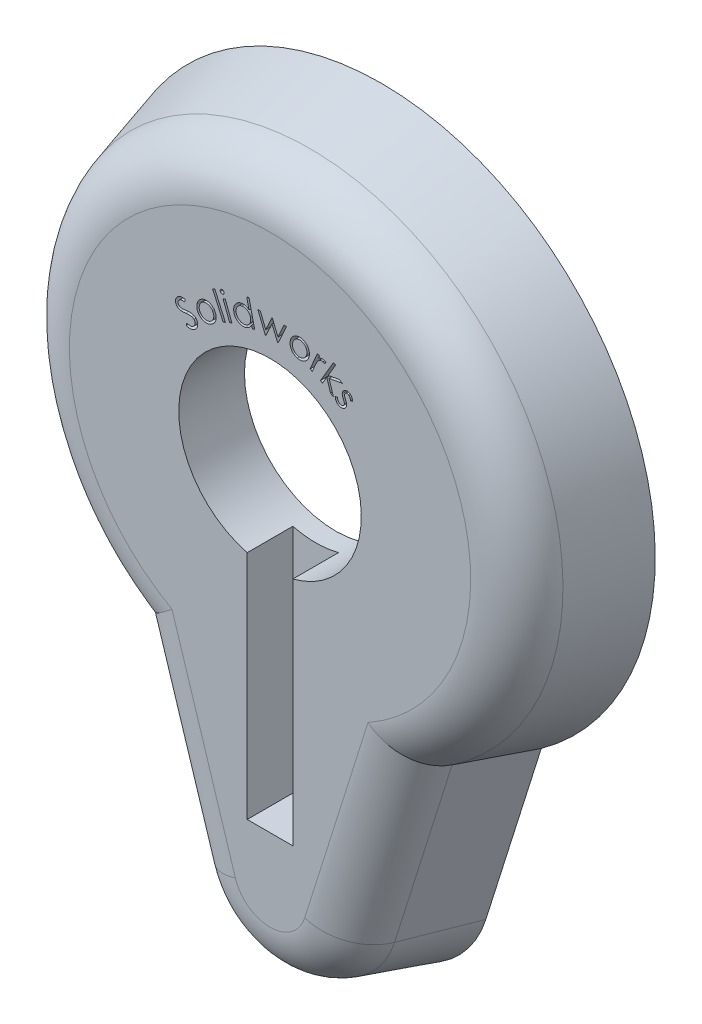
from build123d import *

# Parameters (mm, degrees)
BOSS_EXTRUDE1_DEPTH = 15.494
BOSS_EXTRUDE1_DRAFT = 16
FILLET2_R           = 7.62
CUT_EXTRUDE1_DEPTH  = 6.35
SKETCH3_R           = 12.7
CUT_EXTRUDE3_DEPTH  = 21.336
SKETCH5_W           = 6.35
SKETCH5_H           = 50.8
CUT_EXTRUDE11_DEPTH = 6.35
CUT_EXTRUDE12_DEPTH = 6.35


with BuildPart() as part:
    # Sketch1 → Boss-Extrude1 (with draft: the straight prism first)
    with BuildSketch(Plane.XY):
        with BuildLine():
            Line((-22.24375236, -18.70816137), (-14.534646329, -43.158321986))
            ThreePointArc((-14.534646329, -43.158321986), (0, -53.815565602), (14.534646329, -43.158321986))
            Line((14.534646329, -43.158321986), (22.24375236, -18.70816137))
            ThreePointArc((22.24375236, -18.70816137), (0, 50.324434398), (-22.24375236, -18.70816137))
        make_face()
    extrude(amount=BOSS_EXTRUDE1_DEPTH)
    # Boss-Extrude1: the draft: its side faces are tilted about the plane it starts from
    boss_extrude1_sides = [part.faces().sort_by_distance(p)[0] for p in [
        (0, 50.324434398, 7.747),
        (-18.389199344, -30.933241678, 7.747),
        (0, -53.815565602, 7.747),
        (18.389199344, -30.933241678, 7.747),
    ]]
    draft(boss_extrude1_sides, Plane.XY, BOSS_EXTRUDE1_DRAFT)

    # Fillet2
    fillet2_edges = [part.edges().sort_by_distance(p)[0] for p in [
        (-14.38177278, -28.868491464, 15.494),
        (14.38177278, -28.868491464, 15.494),
        (0, -49.372732595, 15.494),
        (0, 45.881601391, 15.494),
    ]]
    fillet(fillet2_edges, radius=FILLET2_R)

    # Sketch2 → Cut-Extrude1 (cut)
    with BuildSketch(Plane(origin=(0, 0, 0), x_dir=(-1, 0, 0), z_dir=(0, 0, -1))):
        with BuildLine():
            Line((-20.080125275, -17.123515598), (-12.112205275, -42.394529256))
            ThreePointArc((-12.112205275, -42.394529256), (0, -51.275565602), (12.112205275, -42.394529256))
            Line((12.112205275, -42.394529256), (20.080125275, -17.123515598))
            ThreePointArc((20.080125275, -17.123515598), (0, 47.784434398), (-20.080125275, -17.123515598))
        make_face()
    extrude(amount=-CUT_EXTRUDE1_DEPTH, mode=Mode.SUBTRACT)

    # Sketch3 → Cut-Extrude3 (cut)
    with BuildSketch(Plane.XY.offset(15.494)):
        with Locations((0, 12.224434398)):
            Circle(SKETCH3_R)
    extrude(amount=-CUT_EXTRUDE3_DEPTH, mode=Mode.SUBTRACT)

    # Sketch5 → Cut-Extrude11 (cut)
    with BuildSketch(Plane.XY.offset(15.494)):
        with Locations((0, -6.825565602)):
            Rectangle(SKETCH5_W, SKETCH5_H)
    extrude(amount=-CUT_EXTRUDE11_DEPTH, mode=Mode.SUBTRACT)

    # Sketch7 → Cut-Extrude12 (cut)
    with BuildSketch(Plane.XY.offset(15.494)):
        with BuildLine():
            Line((-11.659564973, 23.051406122), (-11.565614653, 23.383737852))
            add(Edge.make_bspline(
                [(-11.565614653, 23.383737852), (-11.515824673, 23.368219435), (-11.420422497, 23.338484723), (-11.279753985, 23.308327924), (-11.148786657, 23.294668516), (-11.027777383, 23.295440211), (-10.916320875, 23.310983606), (-10.814857852, 23.342654393), (-10.722713099, 23.389690715), (-10.670941275, 23.433390753), (-10.645041736, 23.455252275)],
                knots=[0, 0, 0, 0, 0.000156407, 0.00029969, 0.000430777, 0.000550677, 0.000661928, 0.000767036, 0.00086833, 0.000969731, 0.000969731, 0.000969731, 0.000969731], degree=3))
            add(Edge.make_bspline(
                [(-10.645041736, 23.455252275), (-10.624680398, 23.475597204), (-10.58423384, 23.516011168), (-10.532505493, 23.584539197), (-10.491523755, 23.65958612), (-10.458134706, 23.73832204), (-10.436395638, 23.819771721), (-10.423253779, 23.900932155), (-10.424693587, 23.981036026), (-10.435574661, 24.05915034), (-10.457550447, 24.133698386), (-10.487743662, 24.20424153), (-10.52779055, 24.269204192), (-10.561061703, 24.307537603), (-10.577734044, 24.326746666)],
                knots=[0, 0, 0, 0, 8.6286e-05, 0.000171403, 0.000256458, 0.000342265, 0.000427309, 0.000508814, 0.000588044, 0.000666673, 0.000744778, 0.000820454, 0.000896334, 0.00097255, 0.00097255, 0.00097255, 0.00097255], degree=3))
            add(Edge.make_bspline(
                [(-10.577734044, 24.326746666), (-10.598545151, 24.347228902), (-10.640534884, 24.388555087), (-10.717630439, 24.435860668), (-10.803749504, 24.4737013), (-10.866060339, 24.489159309), (-10.898146704, 24.497119263)],
                knots=[0, 0, 0, 0, 8.7345e-05, 0.000176233, 0.000269493, 0.000368498, 0.000368498, 0.000368498, 0.000368498], degree=3))
            add(Edge.make_bspline(
                [(-10.898146704, 24.497119263), (-10.922640324, 24.501627188), (-10.973971466, 24.511074422), (-11.055736468, 24.519700426), (-11.145561842, 24.525247073), (-11.243793313, 24.527090699), (-11.350207091, 24.52588899), (-11.464708356, 24.519545304), (-11.587283862, 24.511761645), (-11.671509074, 24.503026971), (-11.714953595, 24.498521506)],
                knots=[0, 0, 0, 0, 7.4692e-05, 0.000156531, 0.00024645, 0.000344629, 0.000451209, 0.000565629, 0.000688614, 0.000819632, 0.000819632, 0.000819632, 0.000819632], degree=3))
            add(Edge.make_bspline(
                [(-11.714953595, 24.498521506), (-11.758411117, 24.494181597), (-11.841305254, 24.485903328), (-11.960044185, 24.476143159), (-12.067069566, 24.468662321), (-12.162949816, 24.465474396), (-12.247334212, 24.463729629), (-12.320573948, 24.464714691), (-12.382167633, 24.469319786), (-12.419137361, 24.474959978), (-12.4357068, 24.477487852)],
                knots=[0, 0, 0, 0, 0.000131018, 0.000249913, 0.000357414, 0.000452831, 0.000537678, 0.000610608, 0.000672502, 0.000722773, 0.000722773, 0.000722773, 0.000722773], degree=3))
            add(Edge.make_bspline(
                [(-12.4357068, 24.477487852), (-12.460599843, 24.482135514), (-12.509499309, 24.491265301), (-12.579913888, 24.513270812), (-12.647782911, 24.538031014), (-12.711863477, 24.568970859), (-12.772802368, 24.604370168), (-12.830600208, 24.644265131), (-12.884530047, 24.689906847), (-12.917627062, 24.723555094), (-12.934204396, 24.740408525)],
                knots=[0, 0, 0, 0, 7.5903e-05, 0.000149102, 0.000220987, 0.000292487, 0.000362234, 0.000432251, 0.000502901, 0.000573798, 0.000573798, 0.000573798, 0.000573798], degree=3))
            add(Edge.make_bspline(
                [(-12.934204396, 24.740408525), (-12.95855411, 24.768572532), (-13.006419256, 24.823935578), (-13.064727658, 24.916260894), (-13.107918488, 25.01458432), (-13.139513281, 25.117065103), (-13.155053628, 25.222902313), (-13.157780722, 25.32998429), (-13.143857766, 25.437311996), (-13.115735591, 25.543784183), (-13.074029048, 25.646775628), (-13.019221935, 25.743917352), (-12.952853287, 25.834482373), (-12.899430293, 25.887410967), (-12.872505678, 25.91408641)],
                knots=[0, 0, 0, 0, 0.000111586, 0.000219349, 0.000326061, 0.000432972, 0.000540062, 0.000645953, 0.000753353, 0.000863551, 0.00097552, 0.001085706, 0.001197466, 0.001311024, 0.001311024, 0.001311024, 0.001311024], degree=3))
            add(Edge.make_bspline(
                [(-12.872505678, 25.91408641), (-12.842136079, 25.940736967), (-12.781737257, 25.993739386), (-12.678934705, 26.056162735), (-12.569747731, 26.106498379), (-12.472255099, 26.135013452), (-12.389671955, 26.152409457), (-12.322028733, 26.159398938), (-12.249516343, 26.163791066), (-12.172000287, 26.163834666), (-12.089702931, 26.158332112), (-12.002444873, 26.150039112), (-11.910271075, 26.137493916), (-11.847424758, 26.126070886), (-11.815214012, 26.120216218)],
                knots=[0, 0, 0, 0, 0.00012101, 0.000240664, 0.000359267, 0.000480819, 0.000544482, 0.00061223, 0.000684568, 0.000762392, 0.00084457, 0.000931916, 0.00102532, 0.001123527, 0.001123527, 0.001123527, 0.001123527], degree=3))
            Line((-11.815214012, 26.120216218), (-11.87691273, 25.768253077))
            add(Edge.make_bspline(
                [(-11.87691273, 25.768253077), (-11.902830081, 25.772621636), (-11.952705048, 25.781028426), (-12.025469179, 25.790618774), (-12.092943427, 25.798832016), (-12.155436425, 25.802887447), (-12.212747541, 25.804485196), (-12.264949813, 25.803211653), (-12.312292409, 25.799181126), (-12.368000971, 25.789934718), (-12.432453257, 25.771530601), (-12.504373485, 25.739536568), (-12.572458551, 25.698804202), (-12.612410528, 25.663968353), (-12.632722024, 25.646257884)],
                knots=[0, 0, 0, 0, 7.8841e-05, 0.000151721, 0.000220165, 0.000282707, 0.000339515, 0.000392118, 0.000439281, 0.000481929, 0.000561382, 0.000639546, 0.000717585, 0.000798291, 0.000798291, 0.000798291, 0.000798291], degree=3))
            add(Edge.make_bspline(
                [(-12.632722024, 25.646257884), (-12.656320185, 25.622269106), (-12.701924249, 25.575910161), (-12.753535037, 25.495056969), (-12.786637208, 25.408688055), (-12.800269929, 25.318853479), (-12.797012305, 25.229773252), (-12.776609518, 25.144650135), (-12.737987451, 25.065159128), (-12.69992133, 25.02011893), (-12.680398307, 24.997019102)],
                knots=[0, 0, 0, 0, 0.00010074, 0.000194682, 0.000285442, 0.000376274, 0.000465386, 0.000551261, 0.000637176, 0.000727632, 0.000727632, 0.000727632, 0.000727632], degree=3))
            add(Edge.make_bspline(
                [(-12.680398307, 24.997019102), (-12.667091585, 24.983665149), (-12.64050991, 24.956989123), (-12.596036351, 24.921644783), (-12.547568926, 24.891830313), (-12.495127666, 24.865479067), (-12.435952436, 24.845240082), (-12.368740361, 24.830048096), (-12.292961611, 24.81966025), (-12.23942635, 24.816884435), (-12.211347826, 24.815428557)],
                knots=[0, 0, 0, 0, 5.6526e-05, 0.000112918, 0.00016992, 0.000226987, 0.00028863, 0.000356999, 0.000433447, 0.000517769, 0.000517769, 0.000517769, 0.000517769], degree=3))
            add(Edge.make_bspline(
                [(-12.211347826, 24.815428557), (-12.201296982, 24.815613637), (-12.177441363, 24.816052924), (-12.135813251, 24.818255792), (-12.082794047, 24.822738443), (-12.018058653, 24.828362749), (-11.941600631, 24.835256872), (-11.853263273, 24.84446359), (-11.753277771, 24.855826235), (-11.682702367, 24.863809363), (-11.645542537, 24.868012692)],
                knots=[0, 0, 0, 0, 3.0156e-05, 7.1576e-05, 0.000125027, 0.000189774, 0.000266517, 0.000355327, 0.000456213, 0.000568404, 0.000568404, 0.000568404, 0.000568404], degree=3))
            add(Edge.make_bspline(
                [(-11.645542537, 24.868012692), (-11.600466848, 24.873005318), (-11.513003239, 24.88269287), (-11.385291736, 24.891551578), (-11.265586638, 24.896658683), (-11.154026783, 24.897529166), (-11.050636903, 24.894091866), (-10.955313712, 24.88686497), (-10.86798111, 24.874217085), (-10.764198313, 24.852266749), (-10.645793904, 24.815170193), (-10.517080166, 24.755524679), (-10.402395251, 24.681229674), (-10.338662084, 24.619054581), (-10.307101031, 24.588265096)],
                knots=[0, 0, 0, 0, 0.000136041, 0.00026397, 0.000383963, 0.000495443, 0.000598568, 0.000694232, 0.000782082, 0.000863076, 0.00101231, 0.001153144, 0.001287709, 0.001419717, 0.001419717, 0.001419717, 0.001419717], degree=3))
            add(Edge.make_bspline(
                [(-10.307101031, 24.588265096), (-10.286448368, 24.56510366), (-10.245629377, 24.5193262), (-10.194487295, 24.443393403), (-10.151584274, 24.363994808), (-10.116844348, 24.280953891), (-10.091681168, 24.193874662), (-10.074618222, 24.103030679), (-10.067314835, 24.008108058), (-10.068106991, 23.910787475), (-10.076773018, 23.813313968), (-10.095176432, 23.718510167), (-10.121784953, 23.627263529), (-10.157804818, 23.539875229), (-10.202792407, 23.456299864), (-10.256668481, 23.376751962), (-10.318377715, 23.300235315), (-10.365739584, 23.253809706), (-10.389833403, 23.230192179)],
                knots=[0, 0, 0, 0, 9.3006e-05, 0.000183823, 0.000273856, 0.000363438, 0.000453294, 0.00054529, 0.000640256, 0.000738415, 0.000836994, 0.000933385, 0.001027672, 0.001121678, 0.001216412, 0.001311891, 0.001409566, 0.001510708, 0.001510708, 0.001510708, 0.001510708], degree=3))
            add(Edge.make_bspline(
                [(-10.389833403, 23.230192179), (-10.409207613, 23.21282247), (-10.447731818, 23.178284069), (-10.509682632, 23.132281383), (-10.573572902, 23.090763829), (-10.63946536, 23.054052908), (-10.707850154, 23.023270714), (-10.778320375, 22.997124694), (-10.851156103, 22.97605405), (-10.926637841, 22.960561715), (-11.005159091, 22.950771488), (-11.087173544, 22.94653801), (-11.173178432, 22.948789189), (-11.26302593, 22.957611414), (-11.356952957, 22.97145439), (-11.454722112, 22.992141855), (-11.556220028, 23.018755611), (-11.624596743, 23.040358358), (-11.659564973, 23.051406122)],
                knots=[0, 0, 0, 0, 7.8026e-05, 0.00015515, 0.000231188, 0.000306506, 0.000381184, 0.000455942, 0.000531832, 0.000608421, 0.000686862, 0.000769001, 0.000854564, 0.000944701, 0.001039692, 0.001139246, 0.001244342, 0.001354345, 0.001354345, 0.001354345, 0.001354345], degree=3))
        make_face()
        with BuildLine():
            add(Edge.make_bspline(
                [(-9.574275132, 27.261613478), (-9.532672815, 27.286542665), (-9.45102616, 27.335467455), (-9.322358141, 27.393160494), (-9.191906078, 27.436048702), (-9.059543081, 27.465764389), (-8.924822981, 27.477664181), (-8.788598399, 27.476366197), (-8.650470451, 27.460607926), (-8.559557429, 27.438356455), (-8.513477856, 27.427078222)],
                knots=[0, 0, 0, 0, 0.000145403, 0.000285361, 0.000421937, 0.000556846, 0.000691354, 0.000826678, 0.00096504, 0.001107249, 0.001107249, 0.001107249, 0.001107249], degree=3))
            add(Edge.make_bspline(
                [(-8.513477856, 27.427078222), (-8.471842044, 27.414534296), (-8.389574722, 27.389749019), (-8.272025106, 27.339391028), (-8.161573485, 27.279318392), (-8.057006522, 27.210951237), (-7.960699584, 27.130693858), (-7.870901211, 27.041725289), (-7.787812641, 26.942782901), (-7.739484638, 26.870632281), (-7.714900132, 26.833929183)],
                knots=[0, 0, 0, 0, 0.000130375, 0.000257605, 0.000382778, 0.000507231, 0.000631742, 0.000758164, 0.000886086, 0.001018538, 0.001018538, 0.001018538, 0.001018538], degree=3))
            add(Edge.make_bspline(
                [(-7.714900132, 26.833929183), (-7.691898502, 26.796033896), (-7.646468445, 26.721187676), (-7.592838957, 26.602390354), (-7.550254592, 26.4816966), (-7.520707202, 26.357833877), (-7.503213743, 26.231508899), (-7.497706262, 26.102179392), (-7.503950475, 25.970252298), (-7.523074117, 25.837257648), (-7.553100126, 25.706198651), (-7.596744585, 25.580606998), (-7.653287491, 25.462332079), (-7.721485485, 25.35043478), (-7.80336008, 25.246862185), (-7.896942893, 25.149774148), (-8.002880765, 25.05974959), (-8.081051896, 25.007012282), (-8.120849651, 24.980163158)],
                knots=[0, 0, 0, 0, 0.000132882, 0.000262453, 0.000390173, 0.000516354, 0.000643767, 0.000772195, 0.000904157, 0.001039402, 0.001174775, 0.001306929, 0.00143739, 0.001567378, 0.001699219, 0.001832603, 0.001971392, 0.002115332, 0.002115332, 0.002115332, 0.002115332], degree=3))
            add(Edge.make_bspline(
                [(-8.120849651, 24.980163158), (-8.162250393, 24.955299848), (-8.24338713, 24.906572995), (-8.370223816, 24.848242539), (-8.498004315, 24.804261493), (-8.627022655, 24.774626449), (-8.757240478, 24.758864982), (-8.888687403, 24.758461752), (-9.020969238, 24.771891888), (-9.152678647, 24.799225354), (-9.280824869, 24.83918756), (-9.40295782, 24.889041839), (-9.518164734, 24.947553276), (-9.624543493, 25.018152369), (-9.72449593, 25.096945391), (-9.815904594, 25.18685492), (-9.900120931, 25.286055973), (-9.94909911, 25.358514955), (-9.973914555, 25.39522726)],
                knots=[0, 0, 0, 0, 0.000144795, 0.000283767, 0.000417909, 0.00054955, 0.000680172, 0.000810582, 0.000943064, 0.001078368, 0.001213423, 0.001345183, 0.001473749, 0.001600344, 0.001727579, 0.001855001, 0.001984361, 0.002117216, 0.002117216, 0.002117216, 0.002117216], degree=3))
            add(Edge.make_bspline(
                [(-9.973914555, 25.39522726), (-9.996660579, 25.432669625), (-10.041629508, 25.506693248), (-10.094786453, 25.623717806), (-10.138868056, 25.741928662), (-10.168150496, 25.863271188), (-10.188807984, 25.986253931), (-10.194959607, 26.111709386), (-10.191585496, 26.239220337), (-10.179265803, 26.324060546), (-10.173033145, 26.366982068)],
                knots=[0, 0, 0, 0, 0.000131318, 0.000259615, 0.000384928, 0.000509232, 0.000633489, 0.000758486, 0.000885458, 0.001015469, 0.001015469, 0.001015469, 0.001015469], degree=3))
            add(Edge.make_bspline(
                [(-10.173033145, 26.366982068), (-10.163665785, 26.41371461), (-10.145214082, 26.505767764), (-10.102017577, 26.638477098), (-10.04589176, 26.763145696), (-9.976426347, 26.879378087), (-9.89568799, 26.988442769), (-9.800620123, 27.088069127), (-9.693828357, 27.180855554), (-9.614605912, 27.23437013), (-9.574275132, 27.261613478)],
                knots=[0, 0, 0, 0, 0.000142893, 0.000281469, 0.000417654, 0.000552206, 0.000686962, 0.000823851, 0.000964539, 0.001110433, 0.001110433, 0.001110433, 0.001110433], degree=3))
        make_face()
        with BuildLine():
            add(Edge.make_bspline(
                [(-9.399695805, 26.988175978), (-9.427727921, 26.96938), (-9.483032329, 26.932297518), (-9.557255916, 26.86681323), (-9.624848567, 26.796702078), (-9.682927076, 26.719171102), (-9.732847544, 26.635850944), (-9.775532624, 26.546871605), (-9.808808791, 26.451308327), (-9.833869771, 26.351087024), (-9.849671309, 26.248749793), (-9.857245147, 26.146940303), (-9.853732167, 26.046317453), (-9.839339107, 25.947562116), (-9.816384697, 25.850222927), (-9.782859865, 25.754705625), (-9.739685825, 25.660605026), (-9.703417179, 25.600793543), (-9.685052376, 25.570507709)],
                knots=[0, 0, 0, 0, 0.000101149, 0.000199556, 0.000296262, 0.000392877, 0.000489431, 0.000587277, 0.000688395, 0.000792463, 0.000896782, 0.000998686, 0.001098307, 0.001198155, 0.001297638, 0.001397861, 0.001501381, 0.001607566, 0.001607566, 0.001607566, 0.001607566], degree=3))
            add(Edge.make_bspline(
                [(-9.685052376, 25.570507709), (-9.65916723, 25.532577875), (-9.607899955, 25.457455281), (-9.513888042, 25.358774594), (-9.408519892, 25.27347585), (-9.293563563, 25.201428681), (-9.171167629, 25.145540822), (-9.044707072, 25.106150784), (-8.915288598, 25.085937498), (-8.784647455, 25.083082318), (-8.654729336, 25.097918289), (-8.527910425, 25.129636143), (-8.404820001, 25.178193408), (-8.328541235, 25.223095011), (-8.289820004, 25.245888318)],
                knots=[0, 0, 0, 0, 0.000137581, 0.000272488, 0.000407063, 0.000543438, 0.000678347, 0.000809639, 0.000939545, 0.001069984, 0.001200524, 0.00133061, 0.001461196, 0.001595828, 0.001595828, 0.001595828, 0.001595828], degree=3))
            add(Edge.make_bspline(
                [(-8.289820004, 25.245888318), (-8.2528566, 25.271358055), (-8.179904036, 25.321626224), (-8.084193801, 25.412759123), (-8.000949513, 25.513546112), (-7.933366103, 25.625571763), (-7.879475936, 25.744841842), (-7.844579807, 25.871173496), (-7.825969232, 26.002219732), (-7.82585471, 26.136789371), (-7.841561774, 26.271592252), (-7.874821737, 26.402833772), (-7.924681092, 26.529463981), (-7.9706664, 26.607782029), (-7.993946606, 26.647430786)],
                knots=[0, 0, 0, 0, 0.000134488, 0.00026543, 0.000394973, 0.000525559, 0.000656758, 0.000786388, 0.00091737, 0.001052689, 0.001188963, 0.00132347, 0.001457832, 0.001595596, 0.001595596, 0.001595596, 0.001595596], degree=3))
            add(Edge.make_bspline(
                [(-7.993946606, 26.647430786), (-8.013712724, 26.676834762), (-8.052643115, 26.734747413), (-8.120176402, 26.813337769), (-8.192044925, 26.885025952), (-8.271442802, 26.946315663), (-8.35493725, 27.001409495), (-8.445373635, 27.045628931), (-8.5405692, 27.083490072), (-8.640522273, 27.111521701), (-8.742056156, 27.13112619), (-8.842767634, 27.141467323), (-8.941167226, 27.140332648), (-9.037600992, 27.130997889), (-9.131755197, 27.110221576), (-9.224074178, 27.08025147), (-9.313733602, 27.038998777), (-9.370764045, 27.005281089), (-9.399695805, 26.988175978)],
                knots=[0, 0, 0, 0, 0.000106203, 0.000209173, 0.000310314, 0.000410179, 0.000509556, 0.000609892, 0.000711576, 0.00081655, 0.00092078, 0.001021519, 0.001119679, 0.001215535, 0.001311661, 0.001408329, 0.001506218, 0.001607009, 0.001607009, 0.001607009, 0.001607009], degree=3))
        make_face(mode=Mode.SUBTRACT)
        Polygon((-7.983030956, 29.292590762), (-7.679445218, 29.42860839), (-6.216204033, 26.157875217), (-6.51978977, 26.021857589), align=None)
        with BuildLine():
            add(Edge.make_bspline(
                [(-6.759036461, 29.875200476), (-6.741436172, 29.880823056), (-6.70704104, 29.891810908), (-6.652998113, 29.895984536), (-6.599475421, 29.888864933), (-6.548210164, 29.870226455), (-6.500477976, 29.843935928), (-6.458965142, 29.809534867), (-6.426756686, 29.766062865), (-6.411870408, 29.733417223), (-6.404268833, 29.71674695)],
                knots=[0, 0, 0, 0, 5.5282e-05, 0.000108034, 0.000161084, 0.000216076, 0.000270691, 0.000323926, 0.00037651, 0.000431382, 0.000431382, 0.000431382, 0.000431382], degree=3))
            add(Edge.make_bspline(
                [(-6.404268833, 29.71674695), (-6.398561424, 29.699625536), (-6.387350893, 29.665995542), (-6.384415059, 29.612520443), (-6.391430077, 29.559435455), (-6.409113778, 29.507920645), (-6.435324922, 29.460300586), (-6.470406041, 29.419538228), (-6.513274333, 29.38626546), (-6.546453134, 29.371589282), (-6.563423481, 29.364082687)],
                knots=[0, 0, 0, 0, 5.3932e-05, 0.000105933, 0.000158983, 0.000213746, 0.000268362, 0.000321063, 0.000374071, 0.00042957, 0.00042957, 0.00042957, 0.00042957], degree=3))
            add(Edge.make_bspline(
                [(-6.563423481, 29.364082687), (-6.580562188, 29.358671845), (-6.614283701, 29.348025663), (-6.667636506, 29.344886826), (-6.720743047, 29.351953861), (-6.772230978, 29.36963909), (-6.819935539, 29.39579065), (-6.86011772, 29.430857409), (-6.894022417, 29.472091494), (-6.908174745, 29.504578789), (-6.915386622, 29.521133969)],
                knots=[0, 0, 0, 0, 5.3745e-05, 0.000105746, 0.000158795, 0.000213559, 0.000268175, 0.000320876, 0.000372778, 0.000426709, 0.000426709, 0.000426709, 0.000426709], degree=3))
            add(Edge.make_bspline(
                [(-6.915386622, 29.521133969), (-6.921002442, 29.538496233), (-6.932115251, 29.572853369), (-6.936265948, 29.626747846), (-6.928630632, 29.68024456), (-6.911449203, 29.732271568), (-6.884332682, 29.779805838), (-6.850266061, 29.821182692), (-6.807853803, 29.853504543), (-6.775502969, 29.867882252), (-6.759036461, 29.875200476)],
                knots=[0, 0, 0, 0, 5.4607e-05, 0.000108058, 0.000160412, 0.000215841, 0.000271411, 0.000323658, 0.000375682, 0.000429614, 0.000429614, 0.000429614, 0.000429614], degree=3))
        make_face()
        Polygon((-6.535378609, 28.824920027), (-6.22337941, 28.944110732), (-5.303507615, 26.536458489), (-5.615506814, 26.417267784), align=None)
        with BuildLine():
            Line((-2.928785879, 30.779233026), (-2.134414885, 27.310082385))
            Line((-2.134414885, 27.310082385), (-2.451321937, 27.237165718))
            Line((-2.451321937, 27.237165718), (-2.55018011, 27.6676545))
            add(Edge.make_bspline(
                [(-2.55018011, 27.6676545), (-2.575136249, 27.620559778), (-2.624003845, 27.528341753), (-2.712612536, 27.402548397), (-2.809799464, 27.289689444), (-2.917267512, 27.191184454), (-3.034940193, 27.107049852), (-3.161560135, 27.036656466), (-3.297839485, 26.980447085), (-3.393518229, 26.955392114), (-3.442007033, 26.942694564)],
                knots=[0, 0, 0, 0, 0.00015976, 0.000312833, 0.000460444, 0.000605847, 0.000749049, 0.000893419, 0.001039633, 0.001189871, 0.001189871, 0.001189871, 0.001189871], degree=3))
            add(Edge.make_bspline(
                [(-3.442007033, 26.942694564), (-3.485804308, 26.933810163), (-3.572151163, 26.91629446), (-3.702642401, 26.906543551), (-3.830933852, 26.907848164), (-3.957082678, 26.924540178), (-4.08123287, 26.953587714), (-4.203788815, 26.994635709), (-4.323282329, 27.051018891), (-4.439479152, 27.11845145), (-4.549661845, 27.196197539), (-4.650215411, 27.28352044), (-4.740570096, 27.378299309), (-4.819595906, 27.481737997), (-4.888476327, 27.592769427), (-4.946902413, 27.711747294), (-4.994175532, 27.838725741), (-5.017035501, 27.927071957), (-5.028645655, 27.971941359)],
                knots=[0, 0, 0, 0, 0.000133949, 0.000264082, 0.000391704, 0.000518236, 0.000644938, 0.000773756, 0.000905187, 0.001040593, 0.001176379, 0.001309084, 0.001439517, 0.001568531, 0.001698887, 0.001830895, 0.001965556, 0.002104531, 0.002104531, 0.002104531, 0.002104531], degree=3))
            add(Edge.make_bspline(
                [(-5.028645655, 27.971941359), (-5.037757733, 28.01643684), (-5.055723765, 28.104167342), (-5.06624408, 28.236759008), (-5.065400581, 28.367086095), (-5.050345335, 28.495335485), (-5.022842102, 28.621420384), (-4.982901496, 28.745378881), (-4.928822605, 28.866808048), (-4.862838594, 28.984426092), (-4.78712676, 29.096303633), (-4.702158844, 29.198073463), (-4.609704401, 29.289254011), (-4.510160068, 29.369595843), (-4.402138389, 29.438089545), (-4.287172883, 29.496228895), (-4.164447762, 29.544054768), (-4.07866498, 29.565786728), (-4.035156071, 29.576809148)],
                knots=[0, 0, 0, 0, 0.000136144, 0.000268431, 0.000398147, 0.000526597, 0.000655042, 0.00078475, 0.000916591, 0.00105313, 0.001188867, 0.001321277, 0.00145018, 0.001577854, 0.001704276, 0.001833147, 0.001963873, 0.002098419, 0.002098419, 0.002098419, 0.002098419], degree=3))
            add(Edge.make_bspline(
                [(-4.035156071, 29.576809148), (-3.984625539, 29.58703298), (-3.885403301, 29.607108596), (-3.735678682, 29.613817401), (-3.589655988, 29.604619465), (-3.447264598, 29.575928297), (-3.307885689, 29.530549824), (-3.173495734, 29.464545267), (-3.041477413, 29.382596581), (-2.960497503, 29.314933137), (-2.918970174, 29.280234628)],
                knots=[0, 0, 0, 0, 0.000154459, 0.000303296, 0.000448061, 0.000592437, 0.000737882, 0.000886522, 0.001040585, 0.001202751, 0.001202751, 0.001202751, 0.001202751], degree=3))
            Line((-2.918970174, 29.280234628), (-3.24569293, 30.706316359))
            Line((-3.24569293, 30.706316359), (-2.928785879, 30.779233026))
        make_face()
        with BuildLine():
            add(Edge.make_bspline(
                [(-3.939102385, 29.271821167), (-3.983004176, 29.260222652), (-4.069560063, 29.237355255), (-4.191252401, 29.181362077), (-4.305310089, 29.113121129), (-4.40796214, 29.027729992), (-4.499221848, 28.930304285), (-4.577498653, 28.821630044), (-4.639008474, 28.700946932), (-4.686523363, 28.572291086), (-4.717251483, 28.438162654), (-4.730616894, 28.302752602), (-4.727249994, 28.167240255), (-4.710400388, 28.078825192), (-4.701922898, 28.034341199)],
                knots=[0, 0, 0, 0, 0.000135991, 0.000268116, 0.000400264, 0.000533754, 0.00066719, 0.000799878, 0.000934091, 0.001072283, 0.001210388, 0.001345661, 0.001479642, 0.001615308, 0.001615308, 0.001615308, 0.001615308], degree=3))
            add(Edge.make_bspline(
                [(-4.701922898, 28.034341199), (-4.690249456, 27.990936935), (-4.666985319, 27.904436074), (-4.610870063, 27.781606651), (-4.539428392, 27.665385033), (-4.452136169, 27.557844123), (-4.353262663, 27.460963469), (-4.24361583, 27.379364892), (-4.12621102, 27.312606971), (-4.000563344, 27.264158369), (-3.871061176, 27.23137189), (-3.739434456, 27.217630346), (-3.607190277, 27.220237261), (-3.520617012, 27.236630721), (-3.477063123, 27.244878058)],
                knots=[0, 0, 0, 0, 0.000134646, 0.000268338, 0.000403379, 0.000542988, 0.000682809, 0.000817565, 0.000951926, 0.001086682, 0.001220339, 0.001351499, 0.001482656, 0.001615442, 0.001615442, 0.001615442, 0.001615442], degree=3))
            add(Edge.make_bspline(
                [(-3.477063123, 27.244878058), (-3.433855733, 27.256233448), (-3.347674206, 27.278882927), (-3.226170578, 27.335542828), (-3.110315974, 27.404699433), (-3.005072643, 27.491281227), (-2.909523904, 27.588029155), (-2.83074628, 27.696414447), (-2.767078142, 27.81250583), (-2.721796863, 27.937218346), (-2.693249612, 28.067639695), (-2.681000882, 28.202376184), (-2.687178093, 28.340884944), (-2.705106844, 28.432745245), (-2.71424261, 28.479553539)],
                knots=[0, 0, 0, 0, 0.000133775, 0.000266827, 0.000400538, 0.00053763, 0.000674476, 0.000807418, 0.000938242, 0.001070444, 0.001203983, 0.001337729, 0.001475293, 0.001618221, 0.001618221, 0.001618221, 0.001618221], degree=3))
            add(Edge.make_bspline(
                [(-2.71424261, 28.479553539), (-2.723113371, 28.514827822), (-2.740577057, 28.584271583), (-2.778605096, 28.683144794), (-2.822455424, 28.776519893), (-2.875169904, 28.863156039), (-2.936709066, 28.942708167), (-3.005765543, 29.015944553), (-3.082364585, 29.082918979), (-3.166431417, 29.141816333), (-3.254624833, 29.193960059), (-3.346798877, 29.235103119), (-3.440630073, 29.267052966), (-3.536445241, 29.289116403), (-3.634510923, 29.300080923), (-3.734556535, 29.301583597), (-3.836765464, 29.29247299), (-3.904618667, 29.27878006), (-3.939102385, 29.271821167)],
                knots=[0, 0, 0, 0, 0.000109026, 0.000214638, 0.000317186, 0.000418191, 0.000518179, 0.000618369, 0.000719743, 0.000822846, 0.000925902, 0.001026634, 0.001125076, 0.001222874, 0.001320974, 0.001420543, 0.001522613, 0.001628092, 0.001628092, 0.001628092, 0.001628092], degree=3))
        make_face(mode=Mode.SUBTRACT)
        Polygon((-1.696251689, 29.966573705), (-1.355506497, 29.960964731), (-0.600398324, 28.078452712), (0.258475875, 29.932919859), (0.318071227, 29.932218737), (1.10823549, 28.048304475), (1.943271548, 29.903472744), (2.288924593, 29.89786377), (1.127165779, 27.342274827), (1.063363695, 27.343677071), (0.276705041, 29.200948705), (-0.581468035, 27.372423064), (-0.643166753, 27.373124186), align=None)
        with BuildLine():
            add(Edge.make_bspline(
                [(4.47347254, 29.494329916), (4.520326202, 29.481087028), (4.612374857, 29.455070064), (4.7426215, 29.3992256), (4.864151619, 29.333667633), (4.975448026, 29.255005764), (5.077710452, 29.165729815), (5.170123941, 29.064647895), (5.252785555, 28.951926985), (5.299044479, 28.869907233), (5.322531033, 28.828264211)],
                knots=[0, 0, 0, 0, 0.000145931, 0.000286696, 0.000424123, 0.000559505, 0.000694649, 0.000830619, 0.000969592, 0.001112923, 0.001112923, 0.001112923, 0.001112923], degree=3))
            add(Edge.make_bspline(
                [(5.322531033, 28.828264211), (5.341695669, 28.789079192), (5.379677899, 28.711418729), (5.42383425, 28.590552424), (5.455491411, 28.467939877), (5.475342694, 28.343981055), (5.482775376, 28.218376575), (5.479520239, 28.091164456), (5.463449694, 27.962219742), (5.443441706, 27.87715578), (5.433308277, 27.834073506)],
                knots=[0, 0, 0, 0, 0.000130796, 0.000259224, 0.000385233, 0.000510182, 0.00063522, 0.000762172, 0.000891486, 0.001024191, 0.001024191, 0.001024191, 0.001024191], degree=3))
            add(Edge.make_bspline(
                [(5.433308277, 27.834073506), (5.42099767, 27.791279481), (5.396681726, 27.706752605), (5.347020766, 27.585622804), (5.287553723, 27.471506473), (5.216610183, 27.36496019), (5.136068812, 27.265224381), (5.044626682, 27.172858199), (4.943571709, 27.087056357), (4.832760244, 27.009836098), (4.715260683, 26.943036669), (4.593529181, 26.888041107), (4.467664406, 26.849056008), (4.338790773, 26.822395288), (4.206309614, 26.811793063), (4.070838816, 26.813888841), (3.931917504, 26.829816337), (3.839716243, 26.851339484), (3.792683277, 26.862318698)],
                knots=[0, 0, 0, 0, 0.000133508, 0.000263705, 0.000391972, 0.000518953, 0.000647066, 0.00077597, 0.000908294, 0.001044251, 0.001180523, 0.001313289, 0.001444119, 0.00157502, 0.001707308, 0.00184194, 0.001980999, 0.002125799, 0.002125799, 0.002125799, 0.002125799], degree=3))
            add(Edge.make_bspline(
                [(3.792683277, 26.862318698), (3.746148, 26.875775997), (3.654775231, 26.902199621), (3.524546228, 26.954766897), (3.404557481, 27.018913481), (3.294681811, 27.09383584), (3.193437248, 27.178155843), (3.102679689, 27.273973325), (3.022448456, 27.380907168), (2.952403525, 27.496415638), (2.893231557, 27.617594677), (2.845800458, 27.74143806), (2.811434437, 27.866893323), (2.788690387, 27.993350595), (2.778817587, 28.120902544), (2.781850948, 28.249553894), (2.796981474, 28.379444846), (2.816620378, 28.465232463), (2.826537444, 28.508552672)],
                knots=[0, 0, 0, 0, 0.000145261, 0.000285222, 0.000420415, 0.00055265, 0.000683535, 0.000814959, 0.000947612, 0.001083848, 0.001219622, 0.001351658, 0.0014811, 0.001609281, 0.001736563, 0.001864198, 0.001994819, 0.002128064, 0.002128064, 0.002128064, 0.002128064], degree=3))
            add(Edge.make_bspline(
                [(2.826537444, 28.508552672), (2.838621948, 28.550876195), (2.862545757, 28.634664474), (2.911424342, 28.754415338), (2.968958536, 28.867511969), (3.036675735, 28.973110821), (3.113866768, 29.07177884), (3.201846035, 29.162430275), (3.298191397, 29.247197574), (3.369157462, 29.296352193), (3.404962925, 29.321152833)],
                knots=[0, 0, 0, 0, 0.000131962, 0.000261246, 0.0003873, 0.000512163, 0.000636994, 0.000762448, 0.000890667, 0.001021237, 0.001021237, 0.001021237, 0.001021237], degree=3))
            add(Edge.make_bspline(
                [(3.404962925, 29.321152833), (3.445617422, 29.346312067), (3.525954169, 29.396028855), (3.653194564, 29.454834138), (3.783504844, 29.498643509), (3.916207386, 29.528516494), (4.052230389, 29.542488517), (4.19055925, 29.541228115), (4.332217834, 29.527249277), (4.425752642, 29.505451022), (4.47347254, 29.494329916)],
                knots=[0, 0, 0, 0, 0.000143331, 0.000283234, 0.000419367, 0.000555112, 0.000690456, 0.000828578, 0.000969574, 0.001116431, 0.001116431, 0.001116431, 0.001116431], degree=3))
        make_face()
        with BuildLine():
            add(Edge.make_bspline(
                [(4.392142412, 29.178825108), (4.35908683, 29.186549176), (4.293962577, 29.201766701), (4.194915541, 29.212045944), (4.097187985, 29.21204615), (4.000412302, 29.202103685), (3.904687545, 29.182559327), (3.810217473, 29.152149942), (3.71729541, 29.110871134), (3.626536937, 29.06090441), (3.539715534, 29.003317331), (3.460598313, 28.937724539), (3.388369682, 28.866941716), (3.325078877, 28.789095909), (3.269245702, 28.705480854), (3.222394542, 28.615000327), (3.182579158, 28.518644157), (3.163136058, 28.451042871), (3.1532602, 28.416705717)],
                knots=[0, 0, 0, 0, 0.000101757, 0.000200476, 0.000297932, 0.000394486, 0.000491838, 0.000590507, 0.000691595, 0.000796401, 0.000901018, 0.001003627, 0.001104269, 0.001203917, 0.001304062, 0.001405356, 0.001509125, 0.001616241, 0.001616241, 0.001616241, 0.001616241], degree=3))
            add(Edge.make_bspline(
                [(3.1532602, 28.416705717), (3.143470504, 28.37178422), (3.124044413, 28.28264467), (3.115188552, 28.146268846), (3.124522485, 28.010302958), (3.151242568, 27.876598717), (3.193242204, 27.747812067), (3.252357472, 27.628473893), (3.324713412, 27.518323981), (3.412846046, 27.420724353), (3.512081641, 27.334300252), (3.623617605, 27.264898552), (3.74275585, 27.205816447), (3.828422086, 27.181203526), (3.87191004, 27.168708922)],
                knots=[0, 0, 0, 0, 0.000137781, 0.000273404, 0.000408327, 0.000545554, 0.000681465, 0.000813473, 0.000943954, 0.001075542, 0.0012068, 0.001337309, 0.001468705, 0.001604181, 0.001604181, 0.001604181, 0.001604181], degree=3))
            add(Edge.make_bspline(
                [(3.87191004, 27.168708922), (3.91588885, 27.158820181), (4.002658324, 27.139309855), (4.135330216, 27.131840455), (4.266478735, 27.139525836), (4.395149854, 27.166790915), (4.519294354, 27.20999698), (4.636636971, 27.270044442), (4.745542685, 27.346603004), (4.844544369, 27.438495499), (4.932607304, 27.542406121), (5.006935516, 27.656594919), (5.065223916, 27.780383433), (5.091319368, 27.867802857), (5.104482155, 27.911898025)],
                knots=[0, 0, 0, 0, 0.000135027, 0.000266407, 0.000397087, 0.000528129, 0.000659621, 0.000790377, 0.000922255, 0.00105771, 0.001194522, 0.001329875, 0.001465373, 0.001603282, 0.001603282, 0.001603282, 0.001603282], degree=3))
            add(Edge.make_bspline(
                [(5.104482155, 27.911898025), (5.112689455, 27.946585961), (5.128866136, 28.01495628), (5.140260669, 28.11866131), (5.142666371, 28.220523557), (5.134821306, 28.320800199), (5.117448829, 28.419575396), (5.088870531, 28.51663362), (5.051197332, 28.612467273), (5.002463652, 28.704840145), (4.947605878, 28.793056854), (4.885195914, 28.873474992), (4.818173032, 28.946158974), (4.744330689, 29.009784388), (4.664985853, 29.06532061), (4.579809193, 29.112577045), (4.488463894, 29.150840516), (4.424601216, 29.169394747), (4.392142412, 29.178825108)],
                knots=[0, 0, 0, 0, 0.000106849, 0.000210601, 0.000312285, 0.000412143, 0.000511853, 0.00061259, 0.000715184, 0.000820235, 0.000925472, 0.001026443, 0.001125162, 0.001221591, 0.001318259, 0.001415232, 0.001513281, 0.001614624, 0.001614624, 0.001614624, 0.001614624], degree=3))
        make_face(mode=Mode.SUBTRACT)
        with BuildLine():
            Line((6.585675918, 28.79255032), (6.895571751, 28.658636057))
            Line((6.895571751, 28.658636057), (6.746933931, 28.313684134))
            add(Edge.make_bspline(
                [(6.746933931, 28.313684134), (6.783740624, 28.336047138), (6.854687577, 28.379153073), (6.962989513, 28.431371643), (7.067667662, 28.469819776), (7.168858825, 28.49424937), (7.266426235, 28.504931968), (7.36058677, 28.503319095), (7.451468191, 28.487619594), (7.508162056, 28.466051972), (7.536397072, 28.455310737)],
                knots=[0, 0, 0, 0, 0.000129147, 0.000248939, 0.000360055, 0.00046311, 0.000560435, 0.000653708, 0.000744889, 0.000835352, 0.000835352, 0.000835352, 0.000835352], degree=3))
            add(Edge.make_bspline(
                [(7.536397072, 28.455310737), (7.557328267, 28.445185279), (7.600436817, 28.424331533), (7.660051325, 28.379683368), (7.71740077, 28.324270176), (7.751875633, 28.281382765), (7.769870629, 28.258996634)],
                knots=[0, 0, 0, 0, 6.962e-05, 0.000143384, 0.000222225, 0.000308315, 0.000308315, 0.000308315, 0.000308315], degree=3))
            Line((7.769870629, 28.258996634), (7.501340982, 28.071095993))
            add(Edge.make_bspline(
                [(7.501340982, 28.071095993), (7.488889346, 28.083888001), (7.465225215, 28.108199004), (7.429115062, 28.140000909), (7.393731859, 28.164462724), (7.369674691, 28.176287989), (7.358312136, 28.181873237)],
                knots=[0, 0, 0, 0, 5.3543e-05, 0.000101757, 0.000144151, 0.000182096, 0.000182096, 0.000182096, 0.000182096], degree=3))
            add(Edge.make_bspline(
                [(7.358312136, 28.181873237), (7.332421567, 28.191185337), (7.280141306, 28.209989058), (7.194123774, 28.217628449), (7.103772393, 28.208149622), (7.008605079, 28.18437735), (6.910929879, 28.142107984), (6.814958913, 28.076965541), (6.719607743, 27.991966757), (6.661738289, 27.923942749), (6.631248835, 27.888103204)],
                knots=[0, 0, 0, 0, 8.2271e-05, 0.000166127, 0.000256264, 0.000353871, 0.000459376, 0.000573717, 0.000700356, 0.000841377, 0.000841377, 0.000841377, 0.000841377], degree=3))
            add(Edge.make_bspline(
                [(6.631248835, 27.888103204), (6.618385647, 27.871212922), (6.590039772, 27.833992765), (6.549180308, 27.768597235), (6.503776076, 27.690296), (6.454690493, 27.598142366), (6.402587033, 27.492123077), (6.345485353, 27.372934589), (6.285609139, 27.239635903), (6.244619411, 27.146116268), (6.22319595, 27.09723782)],
                knots=[0, 0, 0, 0, 6.3663e-05, 0.000140291, 0.000231083, 0.00033522, 0.000453429, 0.000585458, 0.000731682, 0.000891785, 0.000891785, 0.000891785, 0.000891785], degree=3))
            Line((6.22319595, 27.09723782), (5.878945149, 26.298660095))
            Line((5.878945149, 26.298660095), (5.569049315, 26.432574358))
            Line((5.569049315, 26.432574358), (6.585675918, 28.79255032))
        make_face()
        Polygon((8.835899751, 28.831440685), (9.123359687, 28.661068089), (8.08920504, 26.912470333), (9.642189816, 27.199229147), (10.062161771, 26.95033091), (8.220314816, 26.613091326), (8.822578437, 24.691316487), (8.418732284, 24.930399019), (7.894994303, 26.584345333), (7.306051995, 25.588051262), (7.018592059, 25.758423858), align=None)
        with BuildLine():
            Line((11.508550898, 25.460840609), (11.206367404, 25.422278911))
            add(Edge.make_bspline(
                [(11.206367404, 25.422278911), (11.20207875, 25.451792963), (11.193793879, 25.508808541), (11.175419364, 25.59085663), (11.152620478, 25.666479731), (11.124753354, 25.735669519), (11.091246578, 25.797800525), (11.054483294, 25.854268029), (11.012165497, 25.904172026), (10.979814426, 25.932149533), (10.963779263, 25.946016891)],
                knots=[0, 0, 0, 0, 8.9447e-05, 0.000172795, 0.000251972, 0.000326185, 0.000396133, 0.000463415, 0.000528055, 0.000591583, 0.000591583, 0.000591583, 0.000591583], degree=3))
            add(Edge.make_bspline(
                [(10.963779263, 25.946016891), (10.942765117, 25.961065761), (10.90162838, 25.990525028), (10.832159209, 26.020768417), (10.758364262, 26.035246895), (10.683097661, 26.03662294), (10.610142637, 26.025004098), (10.543477583, 26.001364561), (10.485154738, 25.963962704), (10.454762077, 25.930197425), (10.439340161, 25.913064167)],
                knots=[0, 0, 0, 0, 7.7394e-05, 0.000151504, 0.000225205, 0.00030164, 0.000376217, 0.000445642, 0.00051254, 0.000581453, 0.000581453, 0.000581453, 0.000581453], degree=3))
            add(Edge.make_bspline(
                [(10.439340161, 25.913064167), (10.427113234, 25.89620909), (10.40252968, 25.862320141), (10.379421717, 25.802628161), (10.364488618, 25.737606649), (10.36391668, 25.692071847), (10.363619007, 25.668372661)],
                knots=[0, 0, 0, 0, 6.2226e-05, 0.000125113, 0.000190437, 0.000261338, 0.000261338, 0.000261338, 0.000261338], degree=3))
            add(Edge.make_bspline(
                [(10.363619007, 25.668372661), (10.364376647, 25.655036237), (10.365991232, 25.626615345), (10.372460107, 25.581310384), (10.383903085, 25.531279857), (10.399682218, 25.476165414), (10.419129589, 25.416222666), (10.443429725, 25.351382725), (10.471280212, 25.281399067), (10.492248269, 25.233383368), (10.503142244, 25.208436763)],
                knots=[0, 0, 0, 0, 4.0062e-05, 8.5376e-05, 0.000137088, 0.000193909, 0.000257321, 0.000326088, 0.000401601, 0.00048326, 0.00048326, 0.00048326, 0.00048326], degree=3))
            add(Edge.make_bspline(
                [(10.503142244, 25.208436763), (10.516449261, 25.177677389), (10.542096138, 25.118394235), (10.575785895, 25.030857322), (10.604868646, 24.948780696), (10.62728103, 24.8709435), (10.645055909, 24.798499774), (10.657194056, 24.730622991), (10.664055688, 24.667785258), (10.663814043, 24.627454609), (10.663699135, 24.608276507)],
                knots=[0, 0, 0, 0, 0.000100532, 0.000193758, 0.000281342, 0.000361662, 0.000436656, 0.000505011, 0.000568427, 0.000625923, 0.000625923, 0.000625923, 0.000625923], degree=3))
            add(Edge.make_bspline(
                [(10.663699135, 24.608276507), (10.660439073, 24.572319781), (10.653986928, 24.501156123), (10.623595872, 24.398242915), (10.576795416, 24.301276126), (10.53446612, 24.243103399), (10.512957949, 24.213544936)],
                knots=[0, 0, 0, 0, 0.000108096, 0.000213937, 0.000319925, 0.00042941, 0.00042941, 0.00042941, 0.00042941], degree=3))
            add(Edge.make_bspline(
                [(10.512957949, 24.213544936), (10.496250087, 24.193824236), (10.463290488, 24.154921214), (10.408390489, 24.102902406), (10.349754829, 24.057794746), (10.287946811, 24.01891326), (10.222342661, 23.987180873), (10.153126201, 23.962678376), (10.080581622, 23.944519778), (10.005526403, 23.932401679), (9.929427786, 23.928594605), (9.853965977, 23.930794669), (9.780243619, 23.942417431), (9.70805212, 23.960981421), (9.636894614, 23.985729109), (9.568185654, 24.020278325), (9.500196737, 24.060696148), (9.457697454, 24.093207395), (9.436034872, 24.109778911)],
                knots=[0, 0, 0, 0, 7.7499e-05, 0.000152881, 0.000226365, 0.000299124, 0.00037156, 0.00044452, 0.000519001, 0.000595655, 0.000672193, 0.000747265, 0.000821733, 0.000895534, 0.000970711, 0.00104722, 0.001125858, 0.001207613, 0.001207613, 0.001207613, 0.001207613], degree=3))
            add(Edge.make_bspline(
                [(9.436034872, 24.109778911), (9.408299007, 24.13343713), (9.352945801, 24.18065247), (9.281228172, 24.262968219), (9.2171012, 24.351655511), (9.164446504, 24.448168013), (9.122145205, 24.549378292), (9.093067472, 24.653509471), (9.074270883, 24.759031346), (9.072860407, 24.829985148), (9.072152661, 24.865588206)],
                knots=[0, 0, 0, 0, 0.000109231, 0.000217995, 0.000326558, 0.000437016, 0.000547038, 0.000654902, 0.000760829, 0.000867513, 0.000867513, 0.000867513, 0.000867513], degree=3))
            Line((9.072152661, 24.865588206), (9.381347372, 24.919574584))
            add(Edge.make_bspline(
                [(9.381347372, 24.919574584), (9.383323921, 24.888890724), (9.387161745, 24.829312494), (9.402546337, 24.743628661), (9.422210514, 24.664066446), (9.449278455, 24.591090047), (9.4819342, 24.523881474), (9.522157764, 24.463648725), (9.568071485, 24.409205199), (9.6034155, 24.378349647), (9.621131026, 24.362883879)],
                knots=[0, 0, 0, 0, 9.217e-05, 0.000178965, 0.000260759, 0.000337733, 0.000412045, 0.000484383, 0.000554499, 0.00062496, 0.00062496, 0.00062496, 0.00062496], degree=3))
            add(Edge.make_bspline(
                [(9.621131026, 24.362883879), (9.646915092, 24.344102532), (9.697287609, 24.307410736), (9.782466865, 24.270367918), (9.871861822, 24.25138817), (9.962765629, 24.248834817), (10.051326356, 24.261187474), (10.131874891, 24.291186776), (10.203365592, 24.335894838), (10.240399522, 24.377083738), (10.25915186, 24.397939968)],
                knots=[0, 0, 0, 0, 9.5479e-05, 0.00018653, 0.000276192, 0.000368081, 0.000458115, 0.000542637, 0.00062432, 0.000708106, 0.000708106, 0.000708106, 0.000708106], degree=3))
            add(Edge.make_bspline(
                [(10.25915186, 24.397939968), (10.272718593, 24.416676072), (10.299385505, 24.453503951), (10.326967064, 24.516127891), (10.343730115, 24.582844777), (10.345294822, 24.628975413), (10.346090962, 24.65244718)],
                knots=[0, 0, 0, 0, 6.9227e-05, 0.000136073, 0.000203922, 0.000274206, 0.000274206, 0.000274206, 0.000274206], degree=3))
            add(Edge.make_bspline(
                [(10.346090962, 24.65244718), (10.345134292, 24.665325595), (10.34306979, 24.693117325), (10.334916448, 24.737659765), (10.322004566, 24.787846602), (10.305271333, 24.844105976), (10.283028139, 24.905828503), (10.257212417, 24.973666598), (10.226981577, 25.047612979), (10.204373051, 25.098422183), (10.192545289, 25.12500327)],
                knots=[0, 0, 0, 0, 3.8721e-05, 8.356e-05, 0.000135594, 0.000194153, 0.000259569, 0.000332357, 0.000411909, 0.000499187, 0.000499187, 0.000499187, 0.000499187], degree=3))
            add(Edge.make_bspline(
                [(10.192545289, 25.12500327), (10.179913781, 25.153881351), (10.155452803, 25.209803899), (10.124023703, 25.292438), (10.09786333, 25.370583883), (10.076834742, 25.444269771), (10.060085997, 25.513363376), (10.05053756, 25.578382878), (10.045007856, 25.638829326), (10.045685039, 25.677711288), (10.046010834, 25.696417532)],
                knots=[0, 0, 0, 0, 9.4548e-05, 0.000183092, 0.000265126, 0.00034169, 0.000412949, 0.000478195, 0.000538691, 0.000594781, 0.000594781, 0.000594781, 0.000594781], degree=3))
            add(Edge.make_bspline(
                [(10.046010834, 25.696417532), (10.049247487, 25.731687703), (10.055654059, 25.801500826), (10.086592595, 25.902789912), (10.132695987, 25.99911186), (10.175207534, 26.056936315), (10.19675202, 26.08624125)],
                knots=[0, 0, 0, 0, 0.000106009, 0.000209831, 0.000315819, 0.000424726, 0.000424726, 0.000424726, 0.000424726], degree=3))
            add(Edge.make_bspline(
                [(10.19675202, 26.08624125), (10.212090906, 26.104521962), (10.242203946, 26.140410341), (10.292140937, 26.188549745), (10.346031709, 26.22915037), (10.402104973, 26.264596946), (10.461383428, 26.293380717), (10.523294605, 26.316201529), (10.588600636, 26.331296052), (10.655904943, 26.341092265), (10.724222451, 26.344728784), (10.791924921, 26.341319017), (10.858304472, 26.33043394), (10.923722267, 26.313814136), (10.987868855, 26.289768964), (11.050290416, 26.258543507), (11.111976958, 26.221312239), (11.150772119, 26.191784897), (11.170610193, 26.176685962)],
                knots=[0, 0, 0, 0, 7.1563e-05, 0.00014049, 0.00020752, 0.000273664, 0.000339199, 0.00040485, 0.000471172, 0.000539886, 0.000608685, 0.000676084, 0.000742823, 0.000810164, 0.000878273, 0.000947883, 0.001019308, 0.001094052, 0.001094052, 0.001094052, 0.001094052], degree=3))
            add(Edge.make_bspline(
                [(11.170610193, 26.176685962), (11.193112311, 26.15736954), (11.238397799, 26.118495262), (11.297242473, 26.049429621), (11.349590981, 25.97226883), (11.394728401, 25.886426211), (11.434454661, 25.792544355), (11.466404758, 25.689637059), (11.491498869, 25.578198077), (11.502764855, 25.500661988), (11.508550898, 25.460840609)],
                knots=[0, 0, 0, 0, 8.8855e-05, 0.00017882, 0.00027119, 0.000368109, 0.000469287, 0.000576612, 0.000690912, 0.000811596, 0.000811596, 0.000811596, 0.000811596], degree=3))
        make_face()
    extrude(amount=-CUT_EXTRUDE12_DEPTH, mode=Mode.SUBTRACT)


solid = part.part
